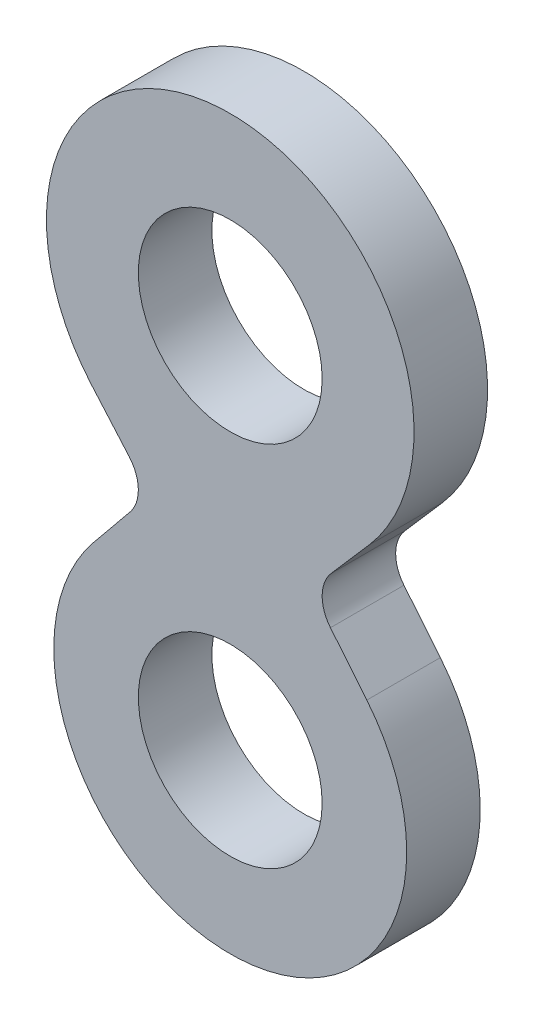
from build123d import *

# Parameters (mm, degrees)
SKETCH1_R           = 15.875
BOSS_EXTRUDE1_DEPTH = 12.7


with BuildPart() as part:
    # Sketch1 → Boss-Extrude1 (new body)
    with BuildSketch(Plane.XY):
        with BuildLine():
            Line((17.434741505, 35.16914378), (23.951292477, 42.6577811))
            ThreePointArc((23.951292477, 42.6577811), (0, 95.25), (-23.951292477, 42.6577811))
            Line((-23.951292477, 42.6577811), (-17.434741505, 35.16914378))
            ThreePointArc((-17.434741505, 35.16914378), (-15.875741954, 31.097768382), (-17.309554442, 26.980638438))
            Line((-17.309554442, 26.980638438), (-23.594138681, 19.296295497))
            ThreePointArc((-23.594138681, 19.296295497), (0, -30.48), (23.594138681, 19.296295497))
            Line((23.594138681, 19.296295497), (17.309554442, 26.980638438))
            ThreePointArc((17.309554442, 26.980638438), (15.875741954, 31.097768382), (17.434741505, 35.16914378))
        make_face()
        with Locations((0, 63.5)):
            Circle(SKETCH1_R, mode=Mode.SUBTRACT)
        Circle(SKETCH1_R, mode=Mode.SUBTRACT)
    extrude(amount=BOSS_EXTRUDE1_DEPTH)


solid = part.part
